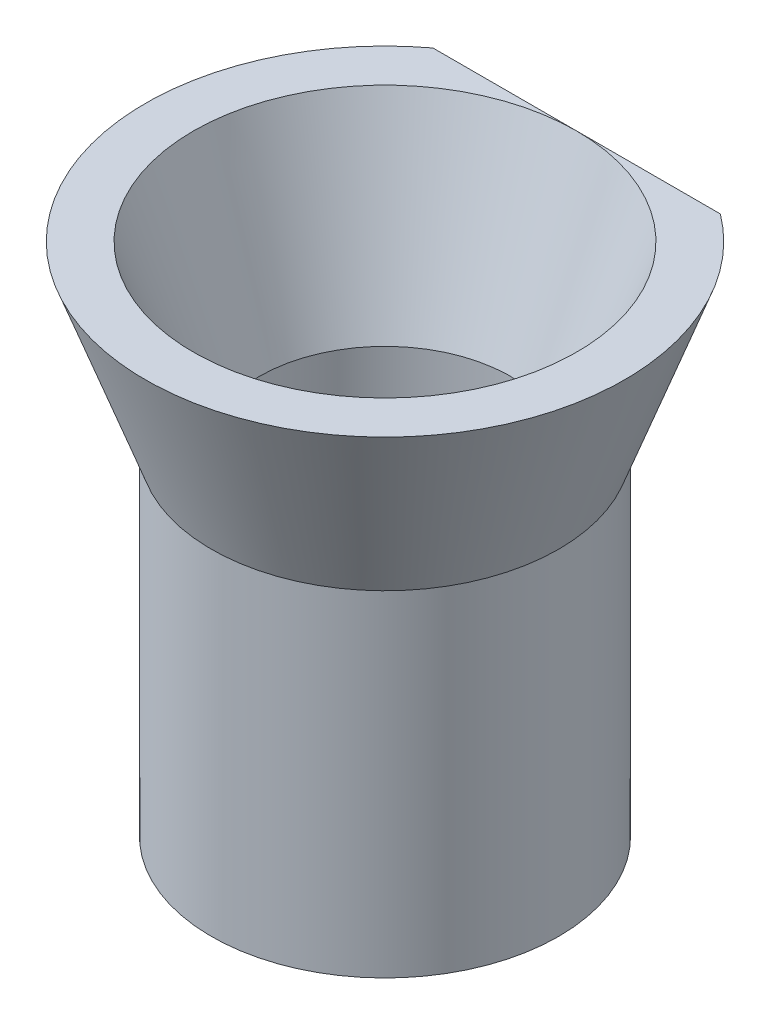
from build123d import *

# Parameters (mm, degrees)
CROQUIS3_R              = 7.25
CROQUIS3_R_2            = 5.25
SALIENTE_EXTRUIR1_DEPTH = 14
CROQUIS4_W              = 14.959615834
CROQUIS4_H              = 3.245468311
CORTAR_EXTRUIR1_DEPTH   = 10


with BuildPart() as part:
    # Croquis2 → Revolución1 (revolve)
    with BuildSketch(Plane.XY):
        Polygon((-5.25, 0), (-8, 7.5), (-10, 7.5), (-7.25, 0), align=None)
    revolve(axis=Axis((0, 7.5, 0), (0, -1, 0)))

    # Croquis3 → Saliente-Extruir1 (add)
    with BuildSketch(Plane.XZ):
        Circle(CROQUIS3_R)
        Circle(CROQUIS3_R_2, mode=Mode.SUBTRACT)
    extrude(amount=SALIENTE_EXTRUIR1_DEPTH)

    # Croquis4 → Cortar-Extruir1 (cut)
    with BuildSketch(Plane(origin=(0, 7.5, 0), x_dir=(1, 0, 0), z_dir=(0, 1, 0))):
        with Locations((0, 9.622734156)):
            Rectangle(CROQUIS4_W, CROQUIS4_H)
    extrude(amount=-CORTAR_EXTRUIR1_DEPTH, mode=Mode.SUBTRACT)


solid = part.part
